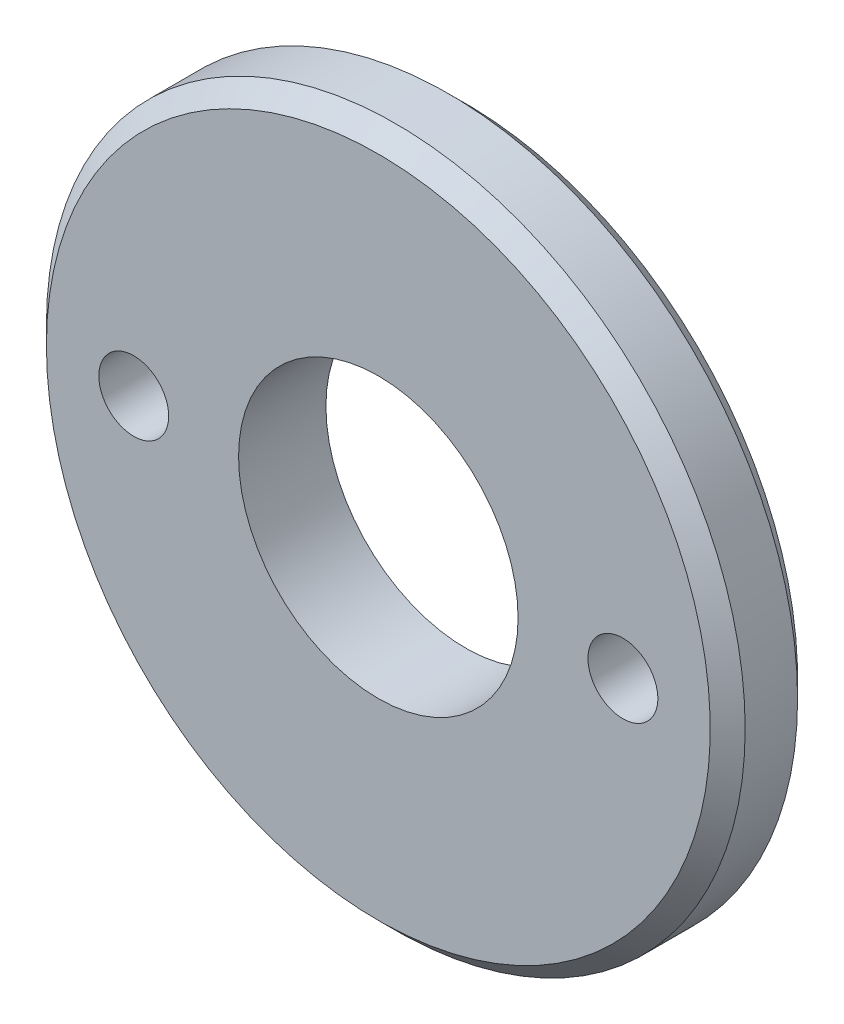
from build123d import *

# Parameters (mm, degrees)
SKETCH1_R           = 12.5
SKETCH1_R_2         = 8
BOSS_EXTRUDE1_DEPTH = 2.5
SKETCH3_R           = 20
SKETCH3_R_2         = 8
BOSS_EXTRUDE3_DEPTH = 5
CHAMFER2_SIZE       = 1
SKETCH5_R           = 12.5
CUT_EXTRUDE1_DEPTH  = 10
CUT_EXTRUDE2_START  = -2
SKETCH6_R           = 2
CUT_EXTRUDE2_DEPTH  = 5


with BuildPart() as part:
    # Sketch1 → Boss-Extrude1 (new body)
    with BuildSketch(Plane.XY):
        Circle(SKETCH1_R)
        Circle(SKETCH1_R_2, mode=Mode.SUBTRACT)
    extrude(amount=BOSS_EXTRUDE1_DEPTH)

    # Sketch3 → Boss-Extrude3 (add)
    with BuildSketch(Plane(origin=(0, 0, 0), x_dir=(-1, 0, 0), z_dir=(0, 0, -1))):
        Circle(SKETCH3_R)
        Circle(SKETCH3_R_2, mode=Mode.SUBTRACT)
    extrude(amount=BOSS_EXTRUDE3_DEPTH)

    # Chamfer2
    chamfer2_edges = [part.edges().sort_by_distance(p)[0] for p in [
        (20, 0, 0),
        (20, 0, -5),
    ]]
    chamfer(chamfer2_edges, length=CHAMFER2_SIZE)

    # Sketch5 → Cut-Extrude1 (cut)
    with BuildSketch(Plane.XY):
        Circle(SKETCH5_R)
    extrude(amount=CUT_EXTRUDE1_DEPTH, mode=Mode.SUBTRACT)

    # Sketch6 → Cut-Extrude2 (cut)
    with BuildSketch(Plane(origin=(0, 0, -5), x_dir=(-1, 0, 0), z_dir=(0, 0, -1)).offset(CUT_EXTRUDE2_START)):
        with Locations((14, 0)):
            Circle(SKETCH6_R)
        with Locations((-14, 0)):
            Circle(SKETCH6_R)
    extrude(amount=-CUT_EXTRUDE2_DEPTH, mode=Mode.SUBTRACT)


solid = part.part
